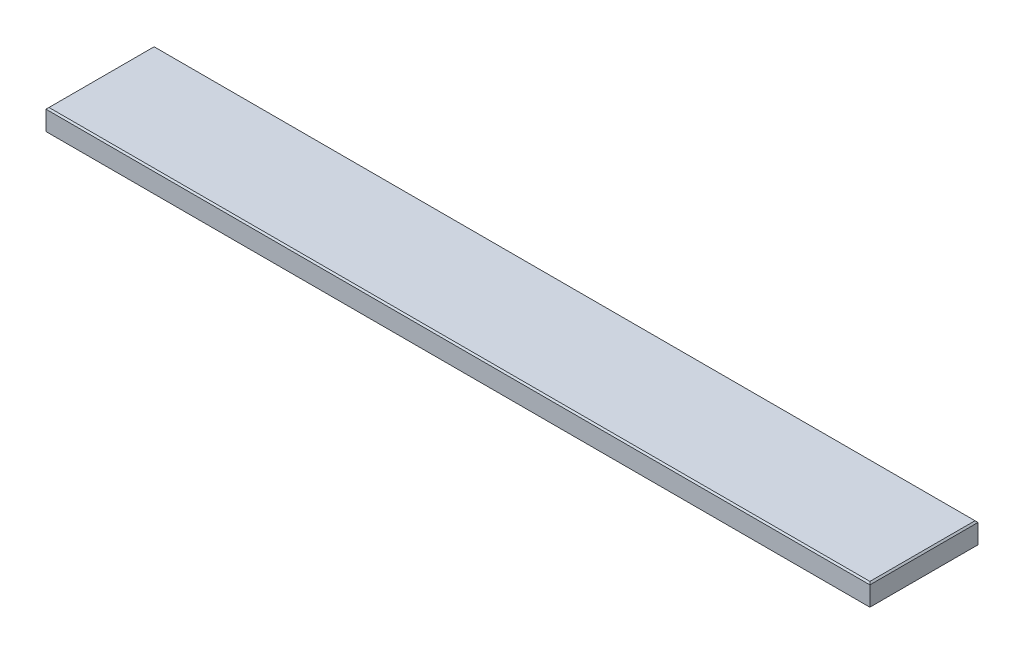
from build123d import *

# Parameters (mm, degrees)
SKETCH1_W           = 1403.35
SKETCH1_H           = 184.15
BOSS_EXTRUDE1_DEPTH = 38.1
CHAMFER1_SIZE       = 2.54


with BuildPart() as part:
    # Sketch1 → Boss-Extrude1 (new body)
    with BuildSketch(Plane(origin=(0, 0, 0), x_dir=(1, 0, 0), z_dir=(0, 1, 0))):
        with Locations((701.675, 92.075)):
            Rectangle(SKETCH1_W, SKETCH1_H)
    extrude(amount=BOSS_EXTRUDE1_DEPTH)

    # Chamfer1
    chamfer1_edges = [part.edges().sort_by_distance(p)[0] for p in [
        (0, 38.1, -92.075),
        (701.675, 38.1, 0),
        (1403.35, 38.1, -92.075),
        (701.675, 0, 0),
        (0, 0, -92.075),
        (701.675, 0, -184.15),
        (1403.35, 0, -92.075),
        (701.675, 38.1, -184.15),
    ]]
    chamfer(chamfer1_edges, length=CHAMFER1_SIZE)


solid = part.part
